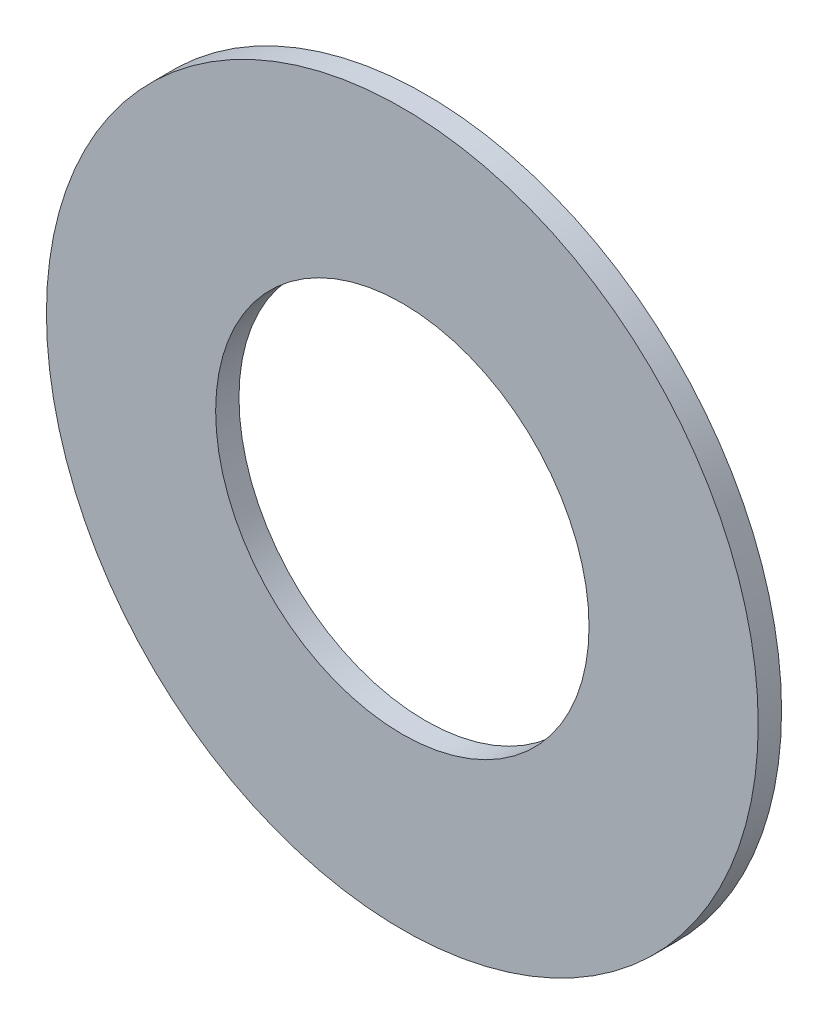
from build123d import *

# Parameters (mm, degrees)
ESQUISSE1_R          = 15.25
ESQUISSE1_R_2        = 8
BASE_EXTRUSION_DEPTH = 1


with BuildPart() as part:
    # Esquisse1 → Base-Extrusion (new body)
    with BuildSketch(Plane.XY):
        Circle(ESQUISSE1_R)
        Circle(ESQUISSE1_R_2, mode=Mode.SUBTRACT)
    extrude(amount=BASE_EXTRUSION_DEPTH)


solid = part.part
